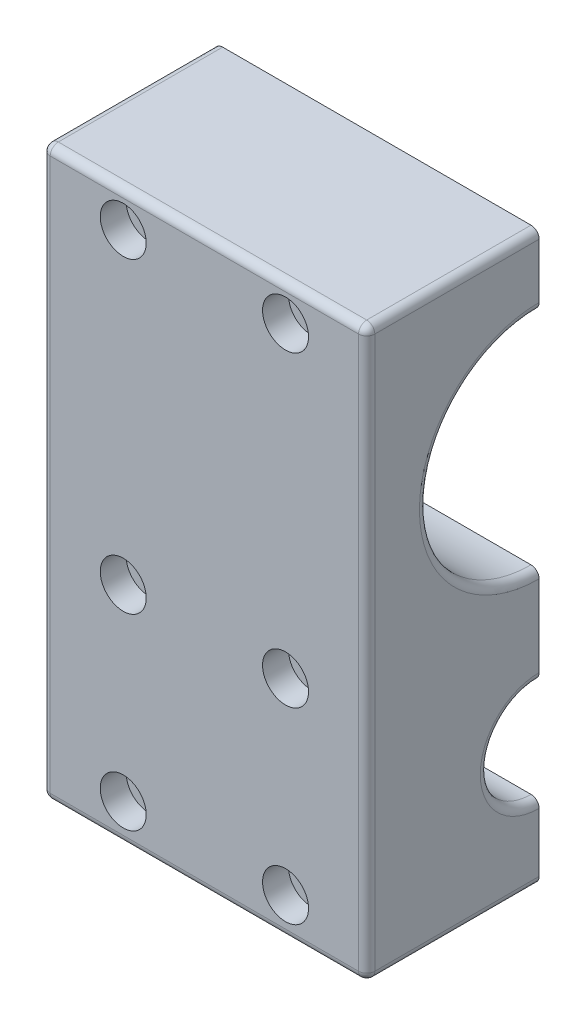
from build123d import *

# Parameters (mm, degrees)
SKETCH1_W           = 53.975
SKETCH1_H           = 88.9
SKETCH1_R           = 7.9375
SKETCH1_R_2         = 17.4625
BOSS_EXTRUDE1_DEPTH = 50.8
SKETCH5_R           = 2.09
CUT_EXTRUDE1_DEPTH  = 116.746060948
SKETCH5_3_R         = 3.6
CUT_EXTRUDE2_DEPTH  = 4.064
CUT_EXTRUDE3_DEPTH  = 2.54
FILLET1_R           = 1.27


with BuildPart() as part:
    # Sketch1 → Boss-Extrude1 (new body)
    with BuildSketch(Plane(origin=(0, 0, 0), x_dir=(0, 0, -1), z_dir=(1, 0, 0))):
        with Locations((26.9875, 44.45)):
            Rectangle(SKETCH1_W, SKETCH1_H)
        with Locations(Location((26.9875, 19.685, 0), (0, 0, 180))):
            Circle(SKETCH1_R, mode=Mode.SUBTRACT)
        with Locations(Location((26.9875, 60.325, 0), (0, 0, 180))):
            Circle(SKETCH1_R_2, mode=Mode.SUBTRACT)
    extrude(amount=BOSS_EXTRUDE1_DEPTH)

    # Sketch5 → Cut-Extrude1 (cut, through all)
    with BuildSketch(Plane.XY):
        with Locations((12.7, 83.34375)):
            Circle(SKETCH5_R)
        with Locations((12.7, 35.2425)):
            Circle(SKETCH5_R)
        with Locations((38.1, 83.34375)):
            Circle(SKETCH5_R)
        with Locations((38.1, 35.2425)):
            Circle(SKETCH5_R)
        with Locations((12.7, 5.87375)):
            Circle(SKETCH5_R)
        with Locations((38.1, 5.87375)):
            Circle(SKETCH5_R)
    extrude(amount=-CUT_EXTRUDE1_DEPTH, mode=Mode.SUBTRACT)

    # Sketch5_3 → Cut-Extrude2 (cut)
    with BuildSketch(Plane.XY):
        with Locations((38.1, 35.2425)):
            Circle(SKETCH5_3_R)
        with Locations((12.7, 83.34375)):
            Circle(SKETCH5_3_R)
        with Locations((38.1, 83.34375)):
            Circle(SKETCH5_3_R)
        with Locations((12.7, 35.2425)):
            Circle(SKETCH5_3_R)
        with Locations((38.1, 5.87375)):
            Circle(SKETCH5_3_R)
        with Locations((12.7, 5.87375)):
            Circle(SKETCH5_3_R)
    extrude(amount=-CUT_EXTRUDE2_DEPTH, mode=Mode.SUBTRACT)

    # Sketch6 → Cut-Extrude3 (cut)
    with BuildSketch(Plane(origin=(0, 0, -53.975), x_dir=(-1, 0, 0), z_dir=(0, 0, -1))):
        Polygon((-34.02855, 83.34375), (-36.064275, 86.86972913), (-40.135725, 86.86972913), (-42.17145, 83.34375), (-40.135725, 79.81777087), (-36.064275, 79.81777087), align=None)
        Polygon((-8.62855, 83.34375), (-10.664275, 86.86972913), (-14.735725, 86.86972913), (-16.77145, 83.34375), (-14.735725, 79.81777087), (-10.664275, 79.81777087), align=None)
        Polygon((-8.62855, 35.2425), (-10.664275, 38.76847913), (-14.735725, 38.76847913), (-16.77145, 35.2425), (-14.735725, 31.71652087), (-10.664275, 31.71652087), align=None)
        Polygon((-34.02855, 35.2425), (-36.064275, 38.76847913), (-40.135725, 38.76847913), (-42.17145, 35.2425), (-40.135725, 31.71652087), (-36.064275, 31.71652087), align=None)
        Polygon((-34.02855, 5.87375), (-36.064275, 9.39972913), (-40.135725, 9.39972913), (-42.17145, 5.87375), (-40.135725, 2.34777087), (-36.064275, 2.34777087), align=None)
        Polygon((-8.62855, 5.87375), (-10.664275, 9.39972913), (-14.735725, 9.39972913), (-16.77145, 5.87375), (-14.735725, 2.34777087), (-10.664275, 2.34777087), align=None)
    extrude(amount=-CUT_EXTRUDE3_DEPTH, mode=Mode.SUBTRACT)

    # Fillet1
    fillet1_edges = [part.edges().sort_by_distance(p)[0] for p in [
        (0, 60.325, -44.45),
        (50.8, 60.325, -44.45),
        (50.8, 88.9, -26.9875),
        (0, 19.685, -34.925),
        (50.8, 19.685, -34.925),
        (50.8, 44.45, 0),
        (50.8, 0, -26.9875),
        (0, 44.45, 0),
        (0, 88.9, -26.9875),
        (0, 44.45, -53.975),
        (0, 0, -26.9875),
        (25.4, 0, 0),
        (25.4, 88.9, 0),
        (25.4, 88.9, -53.975),
        (25.4, 0, -53.975),
        (50.8, 44.45, -53.975),
    ]]
    fillet(fillet1_edges, radius=FILLET1_R)

    # SurfaceCut1
    split(bisect_by=Plane.XY.offset(-26.9875), keep=Keep.TOP)


solid = part.part
